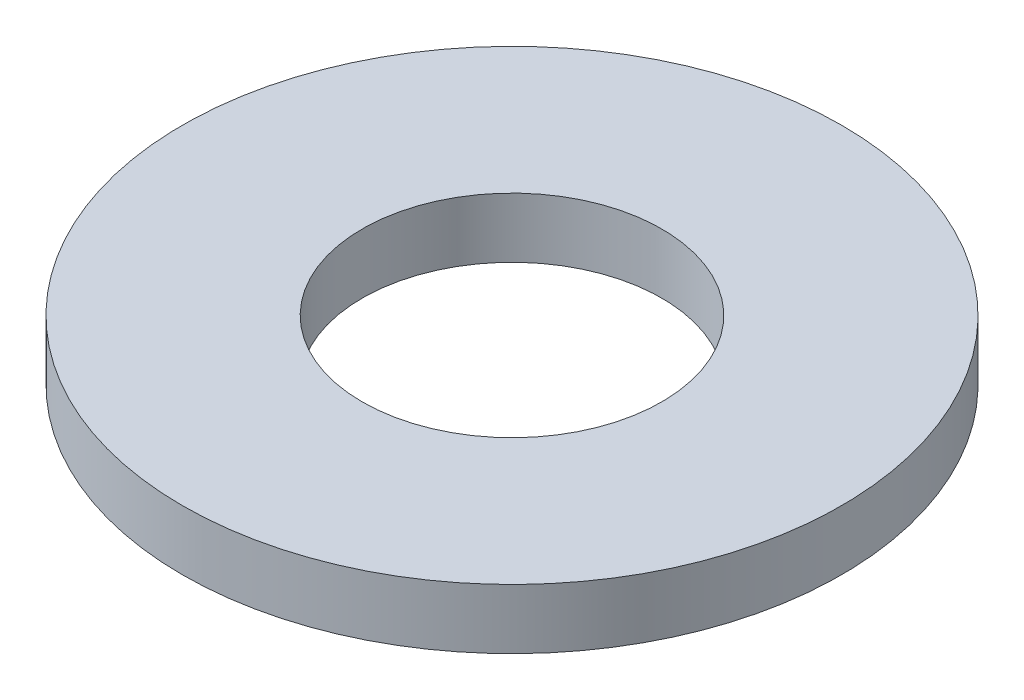
from build123d import *

# Parameters (mm, degrees)
ESQUISSE1_R        = 5.5
ESQUISSE1_R_2      = 2.5
BOSS_EXTRU_1_DEPTH = 1


with BuildPart() as part:
    # Esquisse1 → Boss.-Extru.1 (new body)
    with BuildSketch(Plane(origin=(0, 0, 0), x_dir=(1, 0, 0), z_dir=(0, 1, 0))):
        Circle(ESQUISSE1_R)
        Circle(ESQUISSE1_R_2, mode=Mode.SUBTRACT)
    extrude(amount=BOSS_EXTRU_1_DEPTH)


solid = part.part
